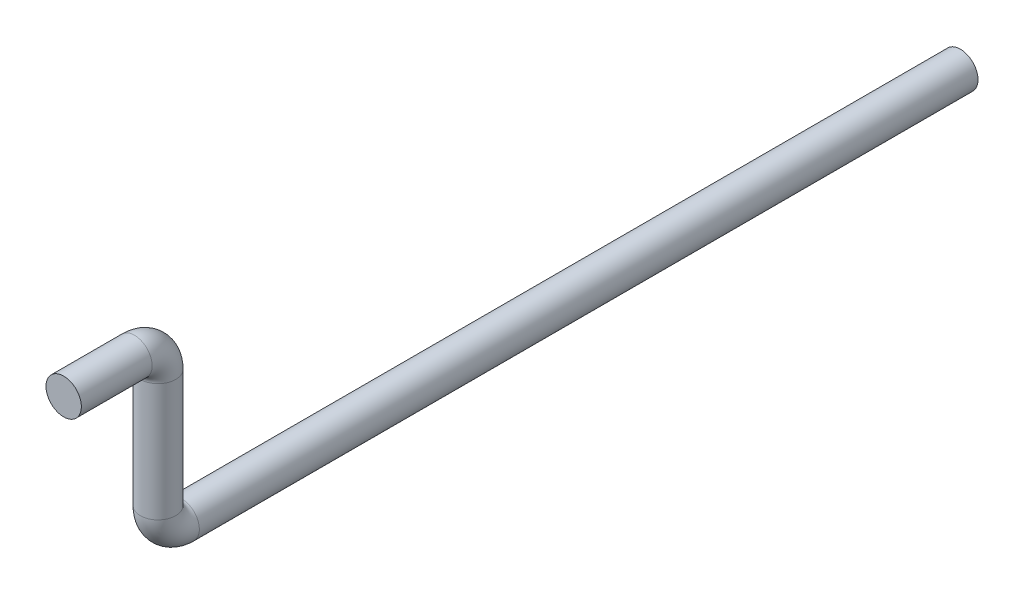
from build123d import *

# Parameters (mm, degrees)
CROQUIS1_R              = 7.5
CROQUIS2_R              = 7.5
SALIENTE_EXTRUIR1_DEPTH = 300


with BuildPart() as part:
    # Barrer1: sweep along a curve in space
    with BuildLine() as barrer1_path:
        Line((0, 0, 0), (0, 0, 30))
        ThreePointArc((0, 0, 30), (0, 2.928932188, 37.071067812), (0, 10, 40))
        Line((0, 10, 40), (0, 60, 40))
        ThreePointArc((0, 60, 40), (0, 67.071067812, 42.928932188), (0, 70, 50))
        Line((0, 70, 50), (0, 70, 80))
    # Croquis1 → Barrer1 (sweep)
    with BuildSketch(Plane.XY):
        Circle(CROQUIS1_R)
    sweep(path=barrer1_path.line)

    # Croquis2 → Saliente-Extruir1 (add)
    with BuildSketch(Plane(origin=(0, 0, 0), x_dir=(-1, 0, 0), z_dir=(0, 0, -1))):
        Circle(CROQUIS2_R)
    extrude(amount=SALIENTE_EXTRUIR1_DEPTH)


solid = part.part
